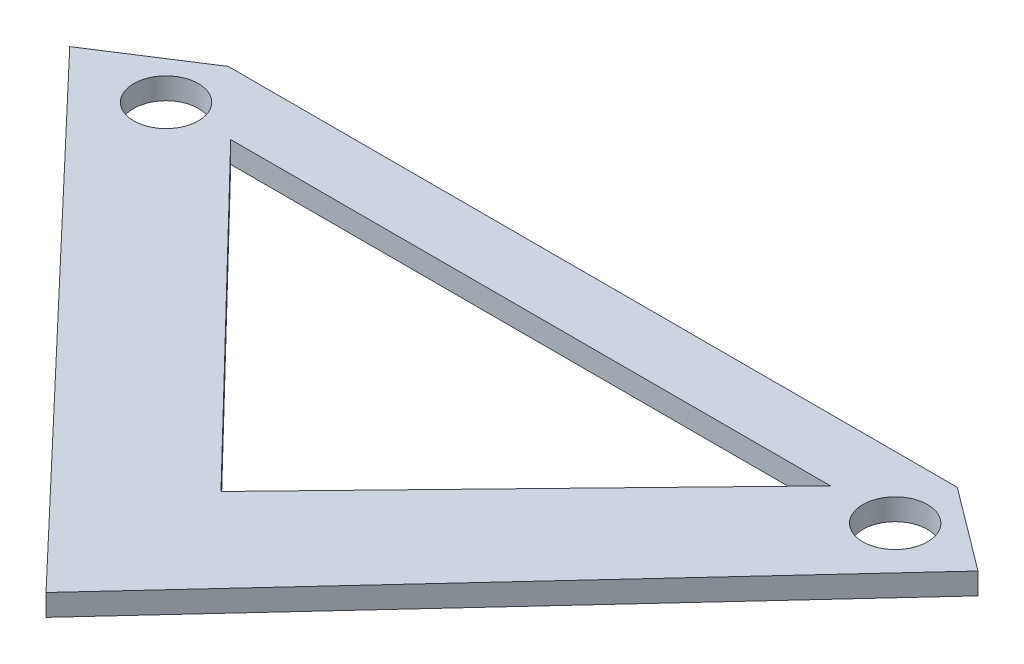
from build123d import *

# Parameters (mm, degrees)
SKETCH_1_R      = 1.5
EXTRUDE_4_DEPTH = 1


with BuildPart() as part:
    # 草图1 → 凸台-拉伸4 (new body)
    with BuildSketch(Plane(origin=(0, 0, 0), x_dir=(1, 0, 0), z_dir=(0, 1, 0))):
        Polygon((-17.435269168, 2.881354455), (16.393730682, 2.881354455), (20.235837144, 0), (-0.520769243, -22.484942941), (-21.903688145, 0), align=None)
        with Locations((-17.435269168, 0)):
            Circle(SKETCH_1_R, mode=Mode.SUBTRACT)
        with Locations((16.393730682, 0)):
            Circle(SKETCH_1_R, mode=Mode.SUBTRACT)
        Polygon((-14.435269168, 0), (0, 0), (13.393730682, 0), (-0.520769243, -14.366164827), align=None, mode=Mode.SUBTRACT)
    extrude(amount=EXTRUDE_4_DEPTH)


solid = part.part
